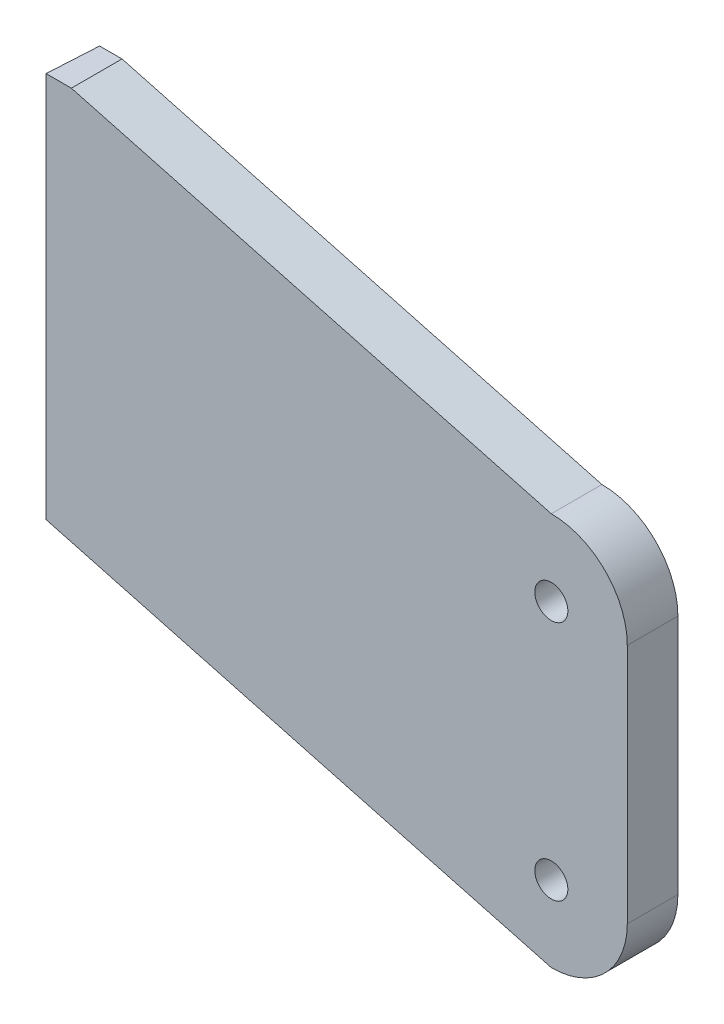
from build123d import *

# Parameters (mm, degrees)
SKETCH1_R               = 3.2639
BOSS_EXTRUDE1_DEPTH     = 10
SKETCH2_W               = 55.96454122
SKETCH2_H               = 39.556429901
BOSS_EXTRUDE2_DEPTH     = 50
CUT_EXTRUDE1_DEPTH      = 3.621876658
CUT_EXTRUDE1_DEPTH_BACK = 57.750909587
CUT_EXTRUDE3_DEPTH      = 104.020815944
BOSS_EXTRUDE3_REACH     = 105.021
SKETCH10_R              = 90
CUT_EXTRUDE4_DEPTH      = 50
CUT_EXTRUDE6_DEPTH      = 2.714029404
CUT_EXTRUDE6_DEPTH_BACK = 57.750909587


with BuildPart() as part:
    # Sketch1 → Boss-Extrude1 (new body)
    with BuildSketch(Plane.XY):
        with BuildLine():
            ThreePointArc((0, -23.8125), (-4.393398282, -34.419101718), (-15, -38.8125))
            Line((-15, -38.8125), (-119.778475404, -10.737192131))
            Line((-119.778475404, -10.737192131), (-119.778475404, 66.887807869))
            Line((-119.778475404, 66.887807869), (-15, 38.8125))
            ThreePointArc((-15, 38.8125), (-4.393398282, 34.419101718), (0, 23.8125))
            Line((0, 23.8125), (0, -23.8125))
        make_face()
        with Locations((-15, 23.8125)):
            Circle(SKETCH1_R, mode=Mode.SUBTRACT)
        with Locations((-15, -23.8125)):
            Circle(SKETCH1_R, mode=Mode.SUBTRACT)
    extrude(amount=BOSS_EXTRUDE1_DEPTH)

    # Sketch2 → Boss-Extrude2 (add)
    with BuildSketch(Plane.XY.offset(10)):
        with Locations((-137.760746014, 83.986530895)):
            Rectangle(SKETCH2_W, SKETCH2_H)
    extrude(amount=-BOSS_EXTRUDE2_DEPTH)

    # Sketch4 → Cut-Extrude1 (cut, two sides)
    with BuildSketch(Plane(origin=(-0.959208406, 0, 16.788657247), x_dir=(0, 1, 0), z_dir=(-0.057041289, 0, 0.99837182))) as cut_extrude1_sk:
        with BuildLine():
            ThreePointArc((64.208315944, 114.013041626), (81.708315944, 131.513041626), (64.208315944, 149.013041626))
            Line((64.208315944, 149.013041626), (64.208315944, 176.700065815))
            Line((64.208315944, 176.700065815), (111.984574651, 176.700065815))
            Line((111.984574651, 176.700065815), (111.984574651, 106.901315277))
            Line((111.984574651, 106.901315277), (64.208315944, 106.901315277))
            Line((64.208315944, 106.901315277), (64.208315944, 114.013041626))
        make_face()
        with BuildLine():
            Line((64.208315944, 144.013041626), (64.208315944, 119.013041626))
            ThreePointArc((64.208315944, 119.013041626), (76.708315944, 131.513041626), (64.208315944, 144.013041626))
        make_face()
    extrude(amount=CUT_EXTRUDE1_DEPTH, mode=Mode.SUBTRACT)
    extrude(cut_extrude1_sk.sketch, amount=-CUT_EXTRUDE1_DEPTH_BACK, mode=Mode.SUBTRACT)

    # Sketch7 → Cut-Extrude3 (cut, through all)
    with BuildSketch(Plane(origin=(0, 64.208315944, 0), x_dir=(1, 0, 0), z_dir=(0, 1, 0))):
        Polygon((-119.778475404, 0), (-119.207132269, 0), (-119.778475404, -10), align=None)
    extrude(amount=-CUT_EXTRUDE3_DEPTH, mode=Mode.SUBTRACT)

    # Boss-Extrude3: up to this face of the body (flat: up to its plane)
    boss_extrude3_end = Plane(part.part.faces().sort_by_distance((-67.246532084, -24.813083921, 5.004556479))[0])
    # Sketch8 → Boss-Extrude3 (add, up to the picked face)
    with BuildSketch(Plane.XZ.offset(-64.208315944), mode=Mode.PRIVATE) as boss_extrude3_sk1:
        Polygon((-119.207132269, 0), (-116.92175973, -40), (-111.913605554, -40), (-114.198978093, 0), align=None)
    boss_extrude3_tool1 = split(extrude(boss_extrude3_sk1.sketch, amount=BOSS_EXTRUDE3_REACH, mode=Mode.PRIVATE), bisect_by=boss_extrude3_end, keep=Keep.BOTH, mode=Mode.PRIVATE)
    add(boss_extrude3_tool1.solids().sort_by_distance((-115.560369, 64.208316, -20))[0])

    # Sketch10 → Cut-Extrude4 (cut)
    with BuildSketch(Plane(origin=(-113.827407897, 0, -6.503450805), x_dir=(0.057041289, 0, -0.99837182), z_dir=(0.99837182, 0, 0.057041289))):
        with Locations((83.472510719, -10.677332841)):
            Circle(SKETCH10_R)
    extrude(amount=-CUT_EXTRUDE4_DEPTH, mode=Mode.SUBTRACT)

    # Sketch14 → Cut-Extrude6 (cut, two sides)
    with BuildSketch(Plane(origin=(-0.959208406, 0, 16.788657247), x_dir=(0, 1, 0), z_dir=(-0.057041289, 0, 0.99837182))) as cut_extrude6_sk:
        Polygon((64.208315944, 114.013041626), (103.707100536, 114.013041626), (103.707100536, 158.820530176), (-53.093138129, 158.820530176), (-49.03095578, 114.013041626), align=None)
    extrude(amount=CUT_EXTRUDE6_DEPTH, mode=Mode.SUBTRACT)
    extrude(cut_extrude6_sk.sketch, amount=-CUT_EXTRUDE6_DEPTH_BACK, mode=Mode.SUBTRACT)


solid = part.part
